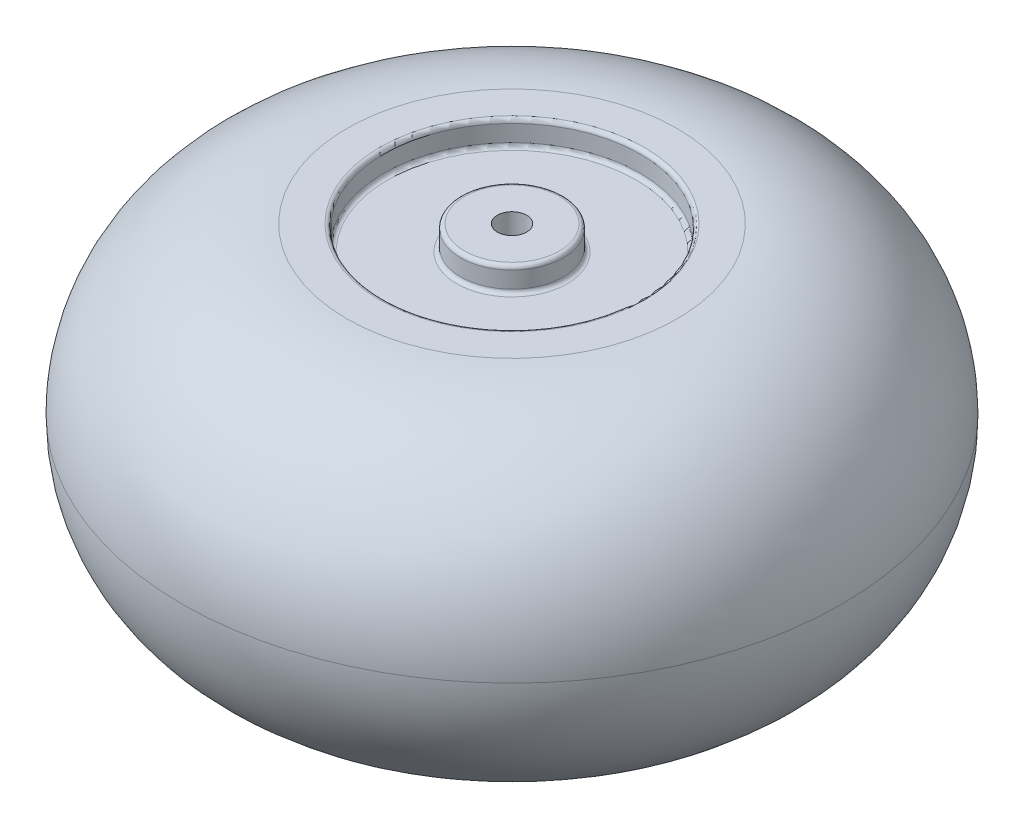
from build123d import *


with BuildPart() as part:
    # Sketch3 → Revolve1 (revolve)
    with BuildSketch(Plane(origin=(0, 0, 0), x_dir=(0, 0, -1), z_dir=(1, 0, 0))):
        with BuildLine():
            Line((6, -67.5), (6, 67.5))
            Line((6, 67.5), (19.386425262, 67.5))
            ThreePointArc((19.386425262, 67.5), (20.527394901, 67.027394901), (21, 65.886425262))
            Line((21, 65.886425262), (21, 59.113574738))
            ThreePointArc((21, 59.113574738), (21.472605099, 57.972605099), (22.613574738, 57.5))
            Line((22.613574738, 57.5), (50.919622929, 57.5))
            ThreePointArc((50.919622929, 57.5), (52.060592569, 57.972605099), (52.533197668, 59.113574738))
            Line((52.533197668, 59.113574738), (52.533197668, 65.886425262))
            ThreePointArc((52.533197668, 65.886425262), (53.005802767, 67.027394901), (54.146772406, 67.5))
            Line((54.146772406, 67.5), (67.533197668, 67.5))
            ThreePointArc((67.533197668, 67.5), (115.200765467, 47.719012588), (134.857324693, 0))
            ThreePointArc((134.857324693, 0), (115.200765467, -47.719012588), (67.533197668, -67.5))
            Line((67.533197668, -67.5), (54.146772406, -67.5))
            ThreePointArc((54.146772406, -67.5), (53.005802767, -67.027394901), (52.533197668, -65.886425262))
            Line((52.533197668, -65.886425262), (52.533197668, -59.113574738))
            ThreePointArc((52.533197668, -59.113574738), (52.060592569, -57.972605099), (50.919622929, -57.5))
            Line((50.919622929, -57.5), (22.613574738, -57.5))
            ThreePointArc((22.613574738, -57.5), (21.472605099, -57.972605099), (21, -59.113574738))
            Line((21, -59.113574738), (21, -65.886425262))
            ThreePointArc((21, -65.886425262), (20.527394901, -67.027394901), (19.386425262, -67.5))
            Line((19.386425262, -67.5), (6, -67.5))
        make_face()
    revolve(axis=Axis((0, 0, 0), (0, 1, 0)))


solid = part.part
